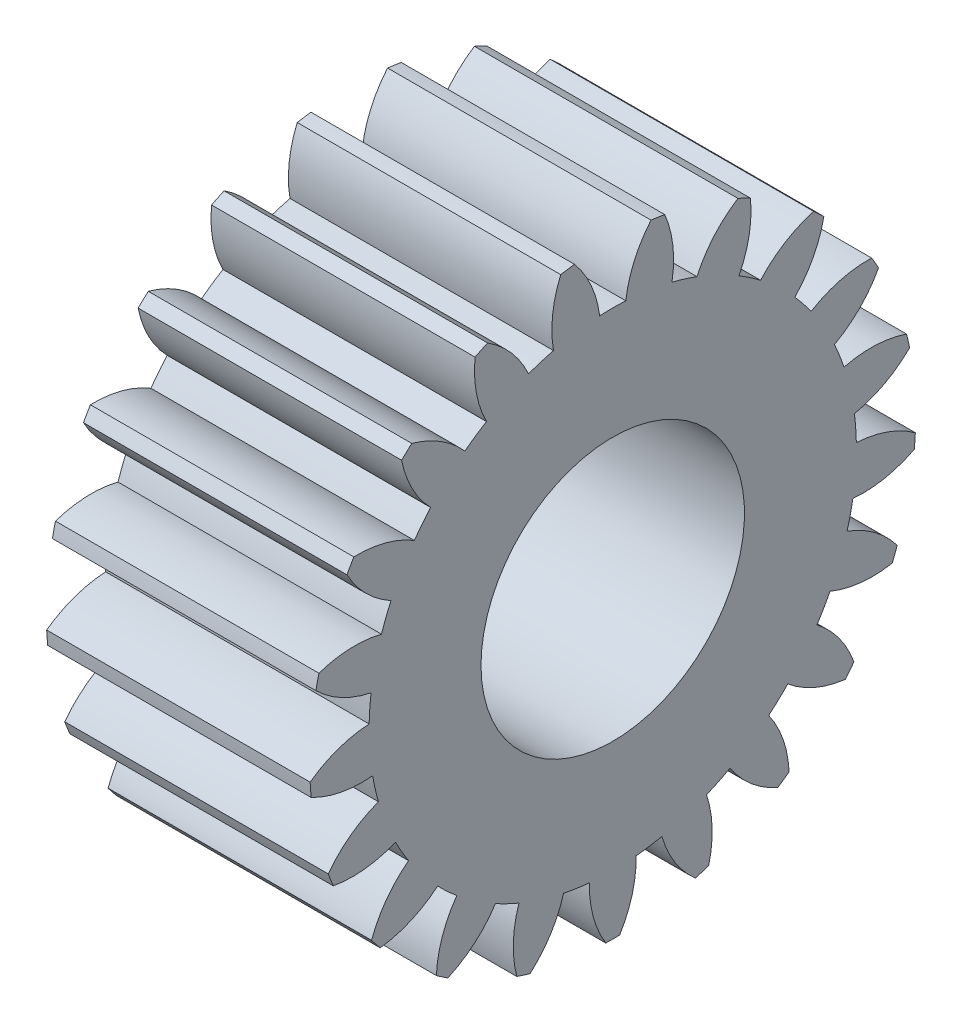
from build123d import *

# Parameters (mm, degrees)
BASPROSKE_W     = 5
BASPROSKE_H     = 5.75
TOOTHCUT_DEPTH  = 10.545941546
TEETHCUTS_COUNT = 21
TEETHCUTS_ANGLE = 342.857142857
BORSKE_R        = 2.5
BORE_DEPTH      = 10.0000508


with BuildPart() as part:
    # BasProSke → Base-Revolve (revolve)
    with BuildSketch(Plane(origin=(0, 0, 0), x_dir=(1, 0, 0), z_dir=(0, 1, 0)), mode=Mode.PRIVATE) as base_revolve_sk:
        with Locations((2.5, 2.875)):
            Rectangle(BASPROSKE_W, BASPROSKE_H)
    revolve(base_revolve_sk.sketch.rotate(Axis((-10, 0, 0), (1, 0, 0)), 180), axis=Axis((-10, 0, 0), (1, 0, 0)))

    # TooCutSke → ToothCut (cut, through all)
    with BuildSketch(Plane(origin=(0, 0, 0), x_dir=(0, 0, -1), z_dir=(1, 0, 0))):
        with BuildLine():
            ThreePointArc((0.247570178, 4.617367757), (0, 4.624), (-0.247570178, 4.617367757))
            ThreePointArc((-0.247570178, 4.617367757), (-0.414765128, 5.209076442), (-0.746177874, 5.726994302))
            ThreePointArc((-0.746177874, 5.726994302), (0, 5.7754), (0.746177874, 5.726994302))
            ThreePointArc((0.746177874, 5.726994302), (0.414765128, 5.209076442), (0.247570178, 4.617367757))
        make_face()
    toothcut = extrude(amount=TOOTHCUT_DEPTH, mode=Mode.SUBTRACT)

    # TeethCuts: ToothCut ×21 about axis
    teethcuts_axis = Axis((-10, 0, 0), (1, 0, 0))
    for i in range(1, TEETHCUTS_COUNT):
        add(toothcut.rotate(teethcuts_axis, i * TEETHCUTS_ANGLE / (TEETHCUTS_COUNT - 1)), mode=Mode.SUBTRACT)

    # BorSke → Bore (cut, symmetric)
    with BuildSketch(Plane(origin=(0, 0, 0), x_dir=(0, 0, -1), z_dir=(1, 0, 0))):
        with Locations(Location((0, 0, 0), (0, 0, 180))):
            Circle(BORSKE_R)
    extrude(amount=BORE_DEPTH, both=True, mode=Mode.SUBTRACT)


solid = part.part
